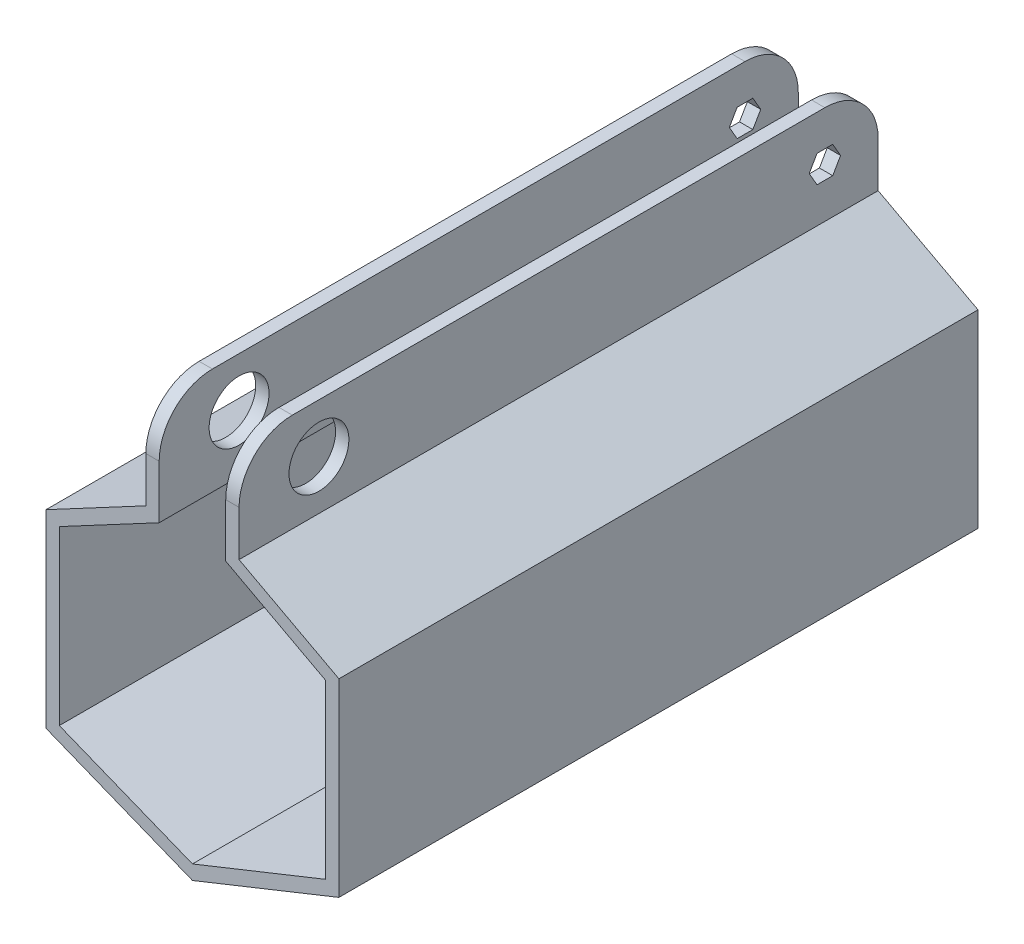
from build123d import *

# Parameters (mm, degrees)
BOSS_EXTRUDE1_DEPTH = 304.8
SKETCH2_R           = 14.2875
CUT_EXTRUDE1_DEPTH  = 304.8
FILLET1_R           = 25.4
FILLET2_R           = 25.4


with BuildPart() as part:
    # Sketch1 → Boss-Extrude1 (new body)
    with BuildSketch(Plane.XY):
        Polygon((0, 0), (-63.5, 25.4), (-63.5, 107.589933746), (-15.875, 132.989933746), (-15.875, 183.789933746), (-22.225, 183.789933746), (-22.225, 136.799933746), (-69.85, 111.399933746), (-69.85, 21.100840695), (0, -6.839159305), (69.85, 21.100840695), (69.85, 111.399933746), (22.225, 136.799933746), (22.225, 183.789933746), (15.875, 183.789933746), (15.875, 132.989933746), (63.5, 107.589933746), (63.5, 25.4), align=None)
    extrude(amount=BOSS_EXTRUDE1_DEPTH)

    # Sketch2 → Cut-Extrude1 (cut)
    with BuildSketch(Plane(origin=(22.225, 0, 0), x_dir=(0, 0, -1), z_dir=(1, 0, 0))):
        with Locations((-266.7, 160.294933746)):
            Circle(SKETCH2_R)
        Polygon((-17.921004613, 160.294933746), (-21.660502306, 166.771933746), (-29.139497694, 166.771933746), (-32.878995387, 160.294933746), (-29.139497694, 153.817933746), (-21.660502306, 153.817933746), align=None)
    extrude(amount=-CUT_EXTRUDE1_DEPTH, mode=Mode.SUBTRACT)

    # Fillet1
    fillet1_edges = [part.edges().sort_by_distance(p)[0] for p in [
        (19.05, 183.789933746, 0),
        (-19.05, 183.789933746, 0),
    ]]
    fillet(fillet1_edges, radius=FILLET1_R)

    # Fillet2
    fillet2_edges = [part.edges().sort_by_distance(p)[0] for p in [
        (-19.05, 183.789933746, 304.8),
        (19.05, 183.789933746, 304.8),
    ]]
    fillet(fillet2_edges, radius=FILLET2_R)


solid = part.part
